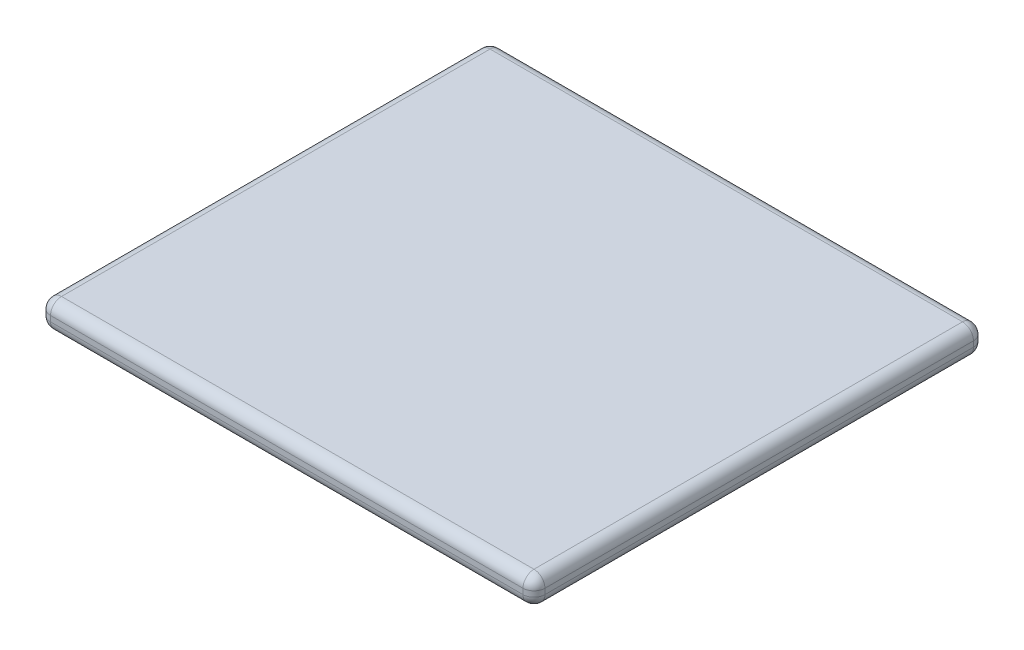
from build123d import *

# Parameters (mm, degrees)
SKETCH1_W           = 450
SKETCH1_H           = 410
BOSS_EXTRUDE1_DEPTH = 25
FILLET1_R           = 10


with BuildPart() as part:
    # Sketch1 → Boss-Extrude1 (new body)
    with BuildSketch(Plane(origin=(0, 0, 0), x_dir=(1, 0, 0), z_dir=(0, 1, 0))):
        with Locations((20, 0)):
            Rectangle(SKETCH1_W, SKETCH1_H)
    extrude(amount=BOSS_EXTRUDE1_DEPTH)

    # Fillet1
    fillet1_edges = [part.edges().sort_by_distance(p)[0] for p in [
        (-205, 25, 0),
        (20, 25, 205),
        (245, 25, 0),
        (20, 0, 205),
        (-205, 0, 0),
        (20, 0, -205),
        (245, 0, 0),
        (245, 12.5, 205),
        (-205, 12.5, 205),
        (-205, 12.5, -205),
        (245, 12.5, -205),
        (20, 25, -205),
    ]]
    fillet(fillet1_edges, radius=FILLET1_R)


solid = part.part
